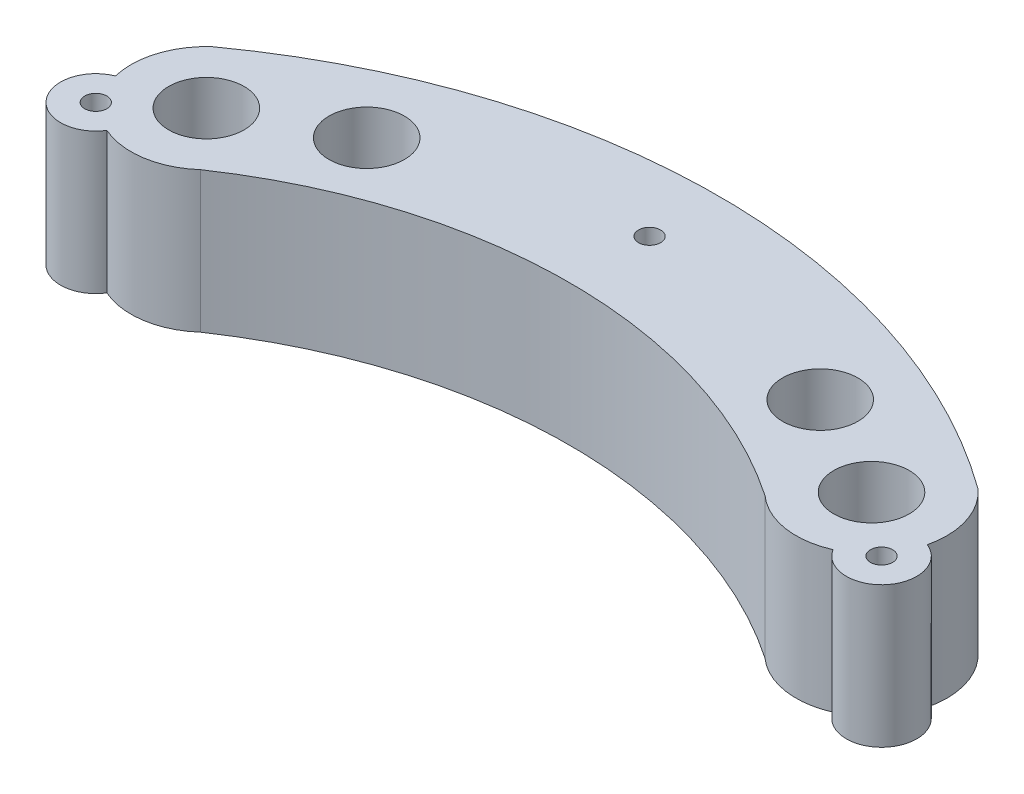
from build123d import *

# Parameters (mm, degrees)
BOSS_EXTRUDE1_DEPTH      = 14.605
BOSS_EXTRUDE1_DEPTH_BACK = 3.175
SKETCH1_R                = 4.7625
CUT_EXTRUDE1_DEPTH       = 20.32
SKETCH4_R                = 2.2225
CUT_EXTRUDE2_DEPTH       = 20.32
SKETCH5_R                = 4.445
BOSS_EXTRUDE2_DEPTH      = 17.78
SKETCH6_R                = 1.397
CUT_EXTRUDE3_DEPTH       = 17.78


with BuildPart() as part:
    # Sketch2 → Boss-Extrude1 (new body, two sides)
    with BuildSketch(Plane(origin=(0, 0, 0), x_dir=(1, 0, 0), z_dir=(0, 1, 0))) as boss_extrude1_sk:
        with BuildLine():
            ThreePointArc((-6.35, 7.099515829), (-7.099515829, -6.35), (6.35, -7.099515829))
            ThreePointArc((6.35, -7.099515829), (42.007194804, 3.857031119), (77.664389608, -7.099515829))
            ThreePointArc((77.664389608, -7.099515829), (91.113905436, -6.35), (90.364389608, 7.099515829))
            ThreePointArc((90.364389608, 7.099515829), (42.007194804, 22.745971747), (-6.35, 7.099515829))
        make_face()
    extrude(amount=BOSS_EXTRUDE1_DEPTH)
    extrude(boss_extrude1_sk.sketch, amount=-BOSS_EXTRUDE1_DEPTH_BACK)

    # Sketch1 → Cut-Extrude1 (cut)
    with BuildSketch(Plane(origin=(0, 0, 0), x_dir=(1, 0, 0), z_dir=(0, 1, 0))):
        Circle(SKETCH1_R)
        with Locations((13.367402776, 6.886065441)):
            Circle(SKETCH1_R)
        with Locations((70.646986832, 6.886065441)):
            Circle(SKETCH1_R)
        with Locations((84.014389608, 0)):
            Circle(SKETCH1_R)
    extrude(amount=CUT_EXTRUDE1_DEPTH, mode=Mode.SUBTRACT)

    # Sketch4 → Cut-Extrude2 (cut)
    with BuildSketch(Plane(origin=(0, 0, 0), x_dir=(1, 0, 0), z_dir=(0, 1, 0))):
        with Locations((13.367402776, 6.886065441)):
            Circle(SKETCH4_R)
        Circle(SKETCH4_R)
        with Locations((70.646986832, 6.886065441)):
            Circle(SKETCH4_R)
        with Locations((84.014389608, 0)):
            Circle(SKETCH4_R)
    extrude(amount=-CUT_EXTRUDE2_DEPTH, mode=Mode.SUBTRACT)

    # Sketch5 → Boss-Extrude2 (add)
    with BuildSketch(Plane(origin=(0, 14.605, 0), x_dir=(1, 0, 0), z_dir=(0, 1, 0))):
        with Locations((-7.62, -6.35)):
            Circle(SKETCH5_R)
        with Locations((91.634389608, -6.35)):
            Circle(SKETCH5_R)
    extrude(amount=-BOSS_EXTRUDE2_DEPTH)

    # Sketch6 → Cut-Extrude3 (cut)
    with BuildSketch(Plane(origin=(0, 14.605, 0), x_dir=(1, 0, 0), z_dir=(0, 1, 0))):
        with Locations((42.007194804, 13.97)):
            Circle(SKETCH6_R)
        with Locations((-7.62, -6.35)):
            Circle(SKETCH6_R)
        with Locations((91.634389608, -6.35)):
            Circle(SKETCH6_R)
    extrude(amount=-CUT_EXTRUDE3_DEPTH, mode=Mode.SUBTRACT)


solid = part.part
